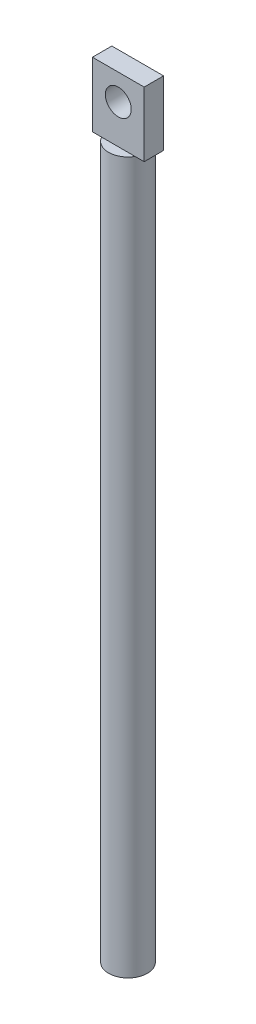
from build123d import *

# Parameters (mm, degrees)
SKETCH1_R           = 1.5
BOSS_EXTRUDE1_DEPTH = 55
SKETCH2_W           = 4
SKETCH2_H           = 1.5
BOSS_EXTRUDE2_DEPTH = 5
SKETCH3_R           = 1
CUT_EXTRUDE1_DEPTH  = 3.25


with BuildPart() as part:
    # Sketch1 → Boss-Extrude1 (new body)
    with BuildSketch(Plane(origin=(0, 0, 0), x_dir=(1, 0, 0), z_dir=(0, 1, 0))):
        Circle(SKETCH1_R)
    extrude(amount=BOSS_EXTRUDE1_DEPTH)

    # Sketch2 → Boss-Extrude2 (add)
    with BuildSketch(Plane(origin=(0, 55, 0), x_dir=(1, 0, 0), z_dir=(0, 1, 0))):
        Rectangle(SKETCH2_W, SKETCH2_H)
    extrude(amount=BOSS_EXTRUDE2_DEPTH)

    # Sketch3 → Cut-Extrude1 (cut, through all)
    with BuildSketch(Plane(origin=(0, 0, -0.75), x_dir=(-1, 0, 0), z_dir=(0, 0, -1))):
        with Locations((0, 58)):
            Circle(SKETCH3_R)
    extrude(amount=-CUT_EXTRUDE1_DEPTH, mode=Mode.SUBTRACT)


solid = part.part
